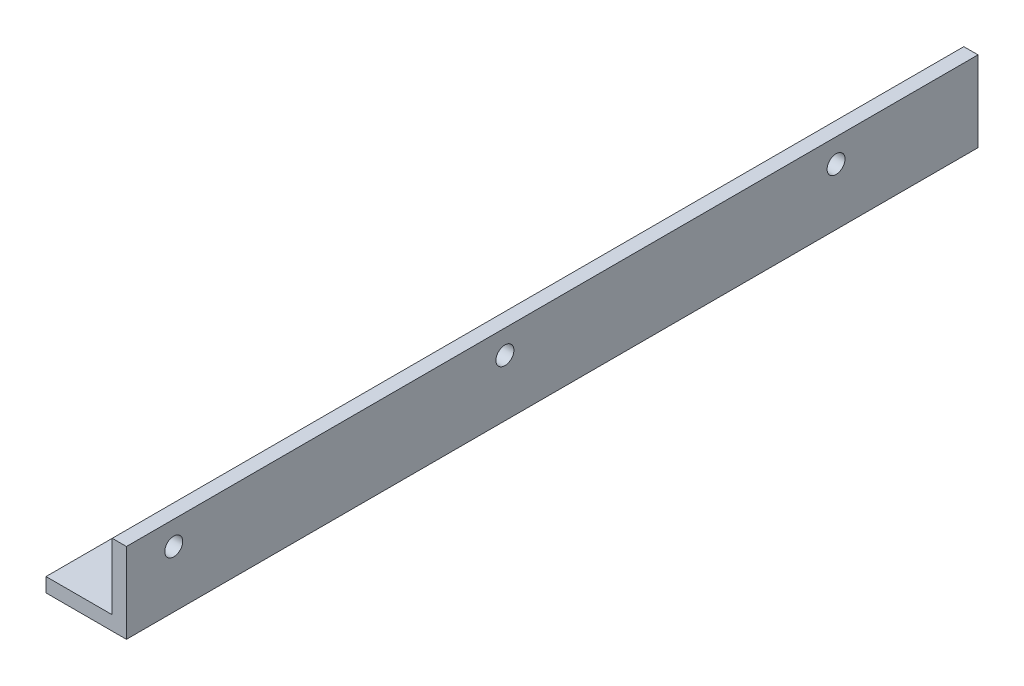
from build123d import *

# Parameters (mm, degrees)
BOSS_EXTRUDE1_DEPTH   = 180
F_6_CLEARANCE_HOLE1_D = 3.7973
F_6_CLEARANCE_HOLE2_D = 3.7973


with BuildPart() as part:
    # Sketch1 → Boss-Extrude1 (new body)
    with BuildSketch(Plane.XY):
        Polygon((0, 0), (0, 17), (-3, 17), (-3, 3), (-17, 3), (-17, 0), align=None)
    extrude(amount=BOSS_EXTRUDE1_DEPTH)

    # #6 Clearance Hole1 (through all)
    with Locations(Plane.ZY.offset(3)):
        with Locations((30, 12), (100, 12), (170, 12)):
            Hole(F_6_CLEARANCE_HOLE1_D / 2)

    # #6 Clearance Hole2 (through all)
    with Locations(Plane(origin=(0, 3, 0), x_dir=(1, 0, 0), z_dir=(0, 1, 0))):
        with Locations((-12, -20), (-12, -90), (-12, -160)):
            Hole(F_6_CLEARANCE_HOLE2_D / 2)


solid = part.part
